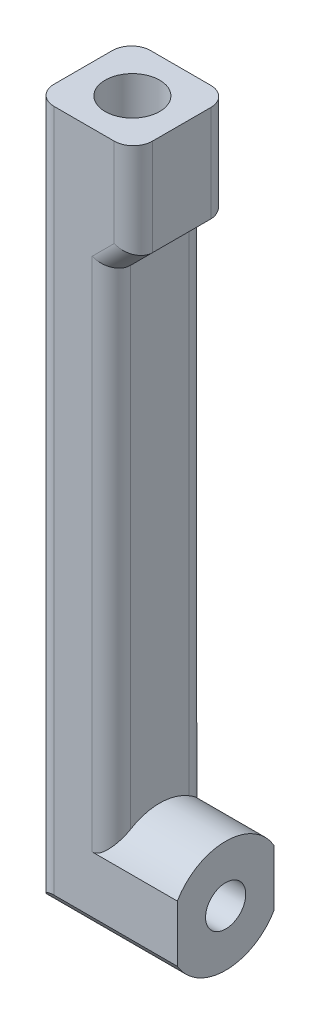
from build123d import *

# Parameters (mm, degrees)
BOSS_EXTRUDE1_DEPTH = 5.05
SKETCH2_R           = 2.1
CUT_EXTRUDE1_DEPTH  = 15.9
SKETCH3_R           = 2.85
CUT_EXTRUDE2_DEPTH  = 9.5
BOSS_EXTRUDE2_DEPTH = 10.1
CUT_EXTRUDE3_DEPTH  = 15.9
CUT_EXTRUDE4_START  = -14.9
CUT_EXTRUDE4_DEPTH  = 6.9
FILLET1_R           = 2


with BuildPart() as part:
    # Sketch1 → Boss-Extrude1 (new body, symmetric)
    with BuildSketch(Plane.XY):
        Polygon((-93.5, 49.48271764), (-108.4, 49.48271764), (-108.4, 123.78957189), (-98.1, 123.78957189), (-98.1, 113.68957189), (-100.4, 113.68957189), (-100.4, 61.18271764), (-93.5, 61.18271764), align=None)
    extrude(amount=BOSS_EXTRUDE1_DEPTH, both=True)

    # Sketch2 → Cut-Extrude1 (cut, through all)
    with BuildSketch(Plane.ZY.offset(108.4)):
        with Locations((0, 55.33271764)):
            Circle(SKETCH2_R)
    extrude(amount=-CUT_EXTRUDE1_DEPTH, mode=Mode.SUBTRACT)

    # Sketch3 → Cut-Extrude2 (cut)
    with BuildSketch(Plane(origin=(0, 123.78957189, 0), x_dir=(1, 0, 0), z_dir=(0, 1, 0))):
        with Locations((-103.25, 0)):
            Circle(SKETCH3_R)
    extrude(amount=-CUT_EXTRUDE2_DEPTH, mode=Mode.SUBTRACT)

    # Sketch5 → Boss-Extrude2 (add)
    with BuildSketch(Plane.XY.offset(5.05)):
        Polygon((-98.1, 113.68957189), (-100.4, 111.38957189), (-100.4, 113.68957189), align=None)
    extrude(amount=-BOSS_EXTRUDE2_DEPTH)

    # Sketch4 → Cut-Extrude3 (cut, through all)
    with BuildSketch(Plane.ZY.offset(108.4)):
        with BuildLine():
            Line((-5.05, 52.379753028), (-5.05, 49.48271764))
            Line((-5.05, 49.48271764), (0, 49.48271764))
            ThreePointArc((0, 49.48271764), (-2.910984114, 50.258402761), (-5.05, 52.379753028))
        make_face()
        with BuildLine():
            ThreePointArc((5.05, 52.379753028), (2.910984114, 50.258402761), (0, 49.48271764))
            Line((0, 49.48271764), (5.05, 49.48271764))
            Line((5.05, 49.48271764), (5.05, 52.379753028))
        make_face()
    extrude(amount=-CUT_EXTRUDE3_DEPTH, mode=Mode.SUBTRACT)

    # Sketch4_3 → Cut-Extrude4 (cut)
    with BuildSketch(Plane.ZY.offset(108.4).offset(CUT_EXTRUDE4_START)):
        with BuildLine():
            Line((-5.05, 61.18271764), (-5.05, 58.285682252))
            ThreePointArc((-5.05, 58.285682252), (-2.910984114, 60.407032519), (0, 61.18271764))
            Line((0, 61.18271764), (-5.05, 61.18271764))
        make_face()
        with BuildLine():
            ThreePointArc((0, 61.18271764), (2.910984114, 60.407032519), (5.05, 58.285682252))
            Line((5.05, 58.285682252), (5.05, 61.18271764))
            Line((5.05, 61.18271764), (0, 61.18271764))
        make_face()
    extrude(amount=CUT_EXTRUDE4_DEPTH, mode=Mode.SUBTRACT)

    # Fillet1
    fillet1_edges = [part.edges().sort_by_distance(p)[0] for p in [
        (-108.4, 88.084662459, -5.05),
        (-100.4, 84.837627071, 5.05),
        (-98.1, 118.73957189, 5.05),
        (-99.25, 112.53957189, 5.05),
        (-99.25, 112.53957189, -5.05),
        (-108.4, 88.084662459, 5.05),
        (-98.1, 118.73957189, -5.05),
        (-100.4, 84.837627071, -5.05),
    ]]
    fillet(fillet1_edges, radius=FILLET1_R)


solid = part.part
